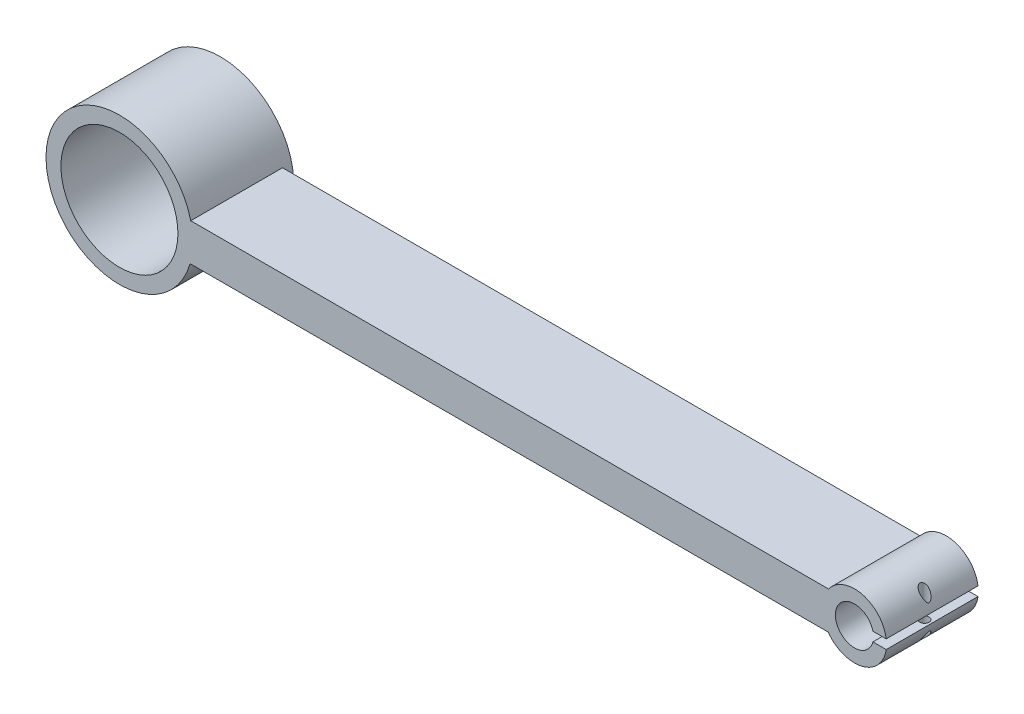
from build123d import *

# Parameters (mm, degrees)
SKETCH1_R               = 4.15
SKETCH1_R_2             = 12.75
BOSS_EXTRUDE1_DEPTH     = 20
SKETCH2_R               = 16
SKETCH2_R_2             = 3.75
SKETCH2_R_3             = 1.5
BOSS_EXTRUDE2_DEPTH     = 2
SKETCH3_W               = 5.093214229
SKETCH3_H               = 2.005927174
CUT_EXTRUDE1_DEPTH      = 23
SKETCH5_R               = 1
CUT_EXTRUDE2_DEPTH      = 18.334595307
CUT_EXTRUDE2_DEPTH_BACK = 15.665404693


with BuildPart() as part:
    # Sketch1 → Boss-Extrude1 (new body)
    with BuildSketch(Plane.XY):
        with BuildLine():
            Line((-160.190785915, 7.025436305), (-21.138691228, 7.025436305))
            ThreePointArc((-21.138691228, 7.025436305), (-8.417687759, 10.994498434), (-21.063816819, 15.196022353))
            Line((-21.063816819, 15.196022353), (-160.043113059, 15.196022353))
            ThreePointArc((-160.043113059, 15.196022353), (-191.581294649, 11.679406985), (-160.190785915, 7.025436305))
        make_face()
        with Locations((-15.417393858, 11.05864302)):
            Circle(SKETCH1_R, mode=Mode.SUBTRACT)
        with Locations((-175.583907283, 11.39027474)):
            Circle(SKETCH1_R_2, mode=Mode.SUBTRACT)
    extrude(amount=BOSS_EXTRUDE1_DEPTH)

    # Sketch2 → Boss-Extrude2 (add)
    with BuildSketch(Plane(origin=(0, 0, 0), x_dir=(-1, 0, 0), z_dir=(0, 0, -1))):
        with Locations((175.583907283, 11.39027474)):
            Circle(SKETCH2_R)
        with Locations((175.583907283, 11.39027474)):
            Circle(SKETCH2_R_2, mode=Mode.SUBTRACT)
        with Locations((184.083907283, 11.39027474)):
            Circle(SKETCH2_R_3, mode=Mode.SUBTRACT)
        with Locations((167.083907283, 11.39027474)):
            Circle(SKETCH2_R_3, mode=Mode.SUBTRACT)
    extrude(amount=BOSS_EXTRUDE2_DEPTH)

    # Sketch3 → Cut-Extrude1 (cut, through all)
    with BuildSketch(Plane.XY.offset(20)):
        with Locations((-9.977016533, 11.05864302)):
            Rectangle(SKETCH3_W, SKETCH3_H)
    extrude(amount=-CUT_EXTRUDE1_DEPTH, mode=Mode.SUBTRACT)

    # Sketch5 → Cut-Extrude2 (cut, two sides)
    with BuildSketch(Plane(origin=(0, 10.055679433, 0), x_dir=(1, 0, 0), z_dir=(0, 1, 0))) as cut_extrude2_sk:
        with Locations((-9.962338035, -10.18638419)):
            Circle(SKETCH5_R)
    extrude(amount=CUT_EXTRUDE2_DEPTH, mode=Mode.SUBTRACT)
    extrude(cut_extrude2_sk.sketch, amount=-CUT_EXTRUDE2_DEPTH_BACK, mode=Mode.SUBTRACT)


solid = part.part
